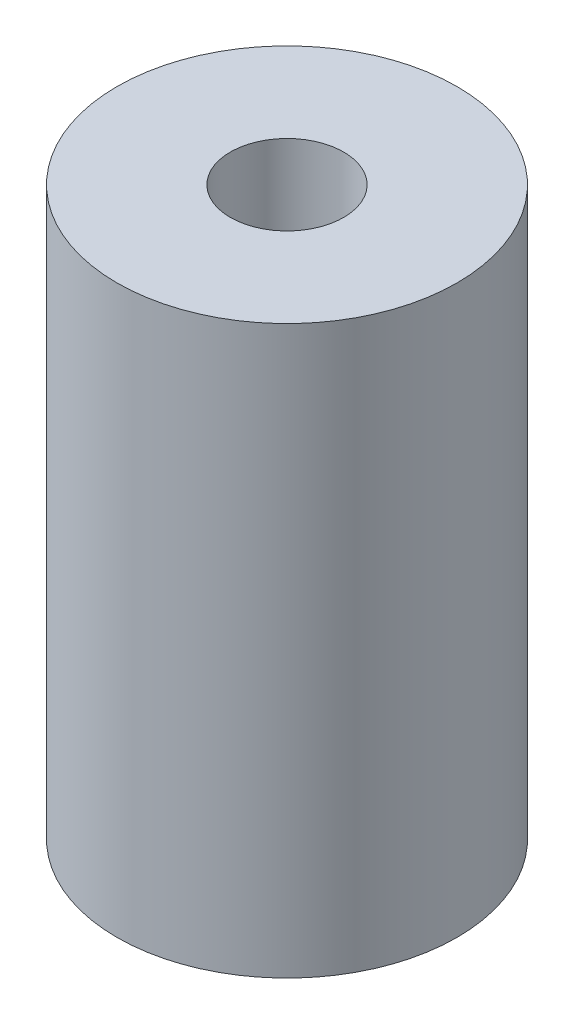
from build123d import *

# Parameters (mm, degrees)
SKETCH1_R           = 15
BOSS_EXTRUDE1_DEPTH = 50
SKETCH2_R           = 5
CUT_EXTRUDE1_DEPTH  = 20
SKETCH3_R           = 5
CUT_EXTRUDE2_DEPTH  = 10


with BuildPart() as part:
    # Sketch1 → Boss-Extrude1 (new body)
    with BuildSketch(Plane(origin=(0, 0, 0), x_dir=(1, 0, 0), z_dir=(0, 1, 0))):
        Circle(SKETCH1_R)
    extrude(amount=BOSS_EXTRUDE1_DEPTH)

    # Sketch2 → Cut-Extrude1 (cut)
    with BuildSketch(Plane.ZY.offset(25)):
        with Locations((0, 25)):
            Circle(SKETCH2_R)
    extrude(amount=-CUT_EXTRUDE1_DEPTH, mode=Mode.SUBTRACT)

    # Sketch3 → Cut-Extrude2 (cut)
    with BuildSketch(Plane(origin=(0, 50, 0), x_dir=(1, 0, 0), z_dir=(0, 1, 0))):
        Circle(SKETCH3_R)
    extrude(amount=-CUT_EXTRUDE2_DEPTH, mode=Mode.SUBTRACT)


solid = part.part
